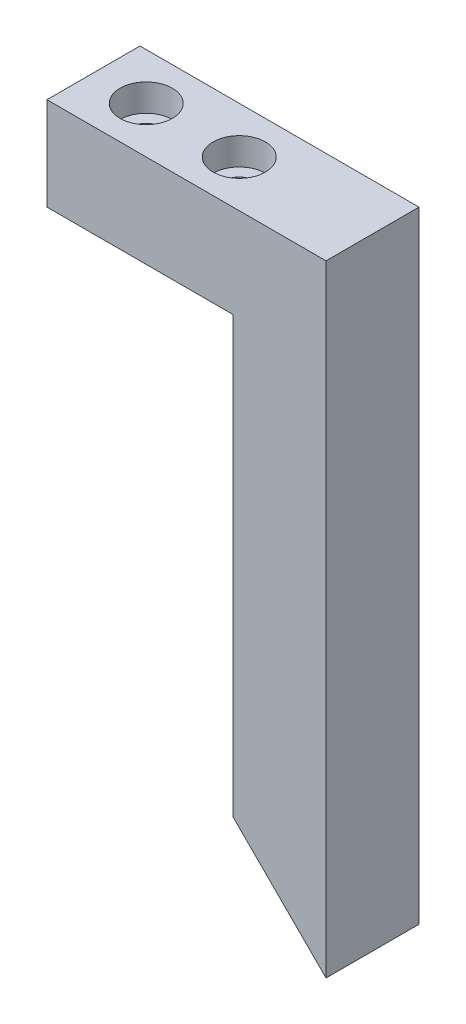
from build123d import *

# Parameters (mm, degrees)
SKETCH1_W                                      = 38.1
SKETCH1_H                                      = 84.8
BOSS_EXTRUDE1_DEPTH                            = 6.35
SKETCH2_W                                      = 25.4
SKETCH2_H                                      = 72.1
CUT_EXTRUDE1_DEPTH                             = 13.7
CBORE_FOR_6_SOCKET_HEAD_CAP_SCREW1_D           = 3.7973
CBORE_FOR_6_SOCKET_HEAD_CAP_SCREW1_CBORE_D     = 7.14502
CBORE_FOR_6_SOCKET_HEAD_CAP_SCREW1_CBORE_DEPTH = 3.7051996
CUT_EXTRUDE2_DEPTH                             = 13.7
F_4_40_TAPPED_HOLE2_D                          = 2.2606
F_4_40_TAPPED_HOLE2_DEPTH                      = 7.59
F_4_40_TAPPED_HOLE2_TIP                        = 0.679152758


with BuildPart() as part:
    # Sketch1 → Boss-Extrude1 (new body, symmetric)
    with BuildSketch(Plane.XY):
        with Locations((19.05, -42.4)):
            Rectangle(SKETCH1_W, SKETCH1_H)
    extrude(amount=BOSS_EXTRUDE1_DEPTH, both=True)

    # Sketch2 → Cut-Extrude1 (cut, through all)
    with BuildSketch(Plane.XY.offset(6.35)):
        with Locations((12.7, -48.75)):
            Rectangle(SKETCH2_W, SKETCH2_H)
    extrude(amount=-CUT_EXTRUDE1_DEPTH, mode=Mode.SUBTRACT)

    # CBORE for #6 Socket Head Cap Screw1 (through all)
    with Locations(Plane(origin=(0, 0, 0), x_dir=(-1, 0, 0), z_dir=(0, 1, 0))):
        with Locations((-7.2, 0), (-19.9, 0)):
            CounterBoreHole(CBORE_FOR_6_SOCKET_HEAD_CAP_SCREW1_D / 2, CBORE_FOR_6_SOCKET_HEAD_CAP_SCREW1_CBORE_D / 2, CBORE_FOR_6_SOCKET_HEAD_CAP_SCREW1_CBORE_DEPTH)

    # Sketch9 → Cut-Extrude2 (cut, through all)
    with BuildSketch(Plane.XY.offset(6.35)):
        Polygon((38.1, -84.8), (24.4, -71.1), (24.4, -85.8), (38.1, -85.8), align=None)
    extrude(amount=-CUT_EXTRUDE2_DEPTH, mode=Mode.SUBTRACT)

    # #4-40 Tapped Hole2
    with Locations(Plane(origin=(-23.35, -23.35, 0), x_dir=(-0.707106781, 0.707106781, 0), z_dir=(-0.707106781, -0.707106781, 0))):
        with Locations((-77.923167287, 3.175), (-77.923167287, -3.175)):
            Hole(F_4_40_TAPPED_HOLE2_D / 2, depth=F_4_40_TAPPED_HOLE2_DEPTH)
            with Locations((0, 0, -(F_4_40_TAPPED_HOLE2_DEPTH + F_4_40_TAPPED_HOLE2_TIP / 2))):  # 118° drill point
                Cone(0, F_4_40_TAPPED_HOLE2_D / 2, F_4_40_TAPPED_HOLE2_TIP, mode=Mode.SUBTRACT)


solid = part.part
